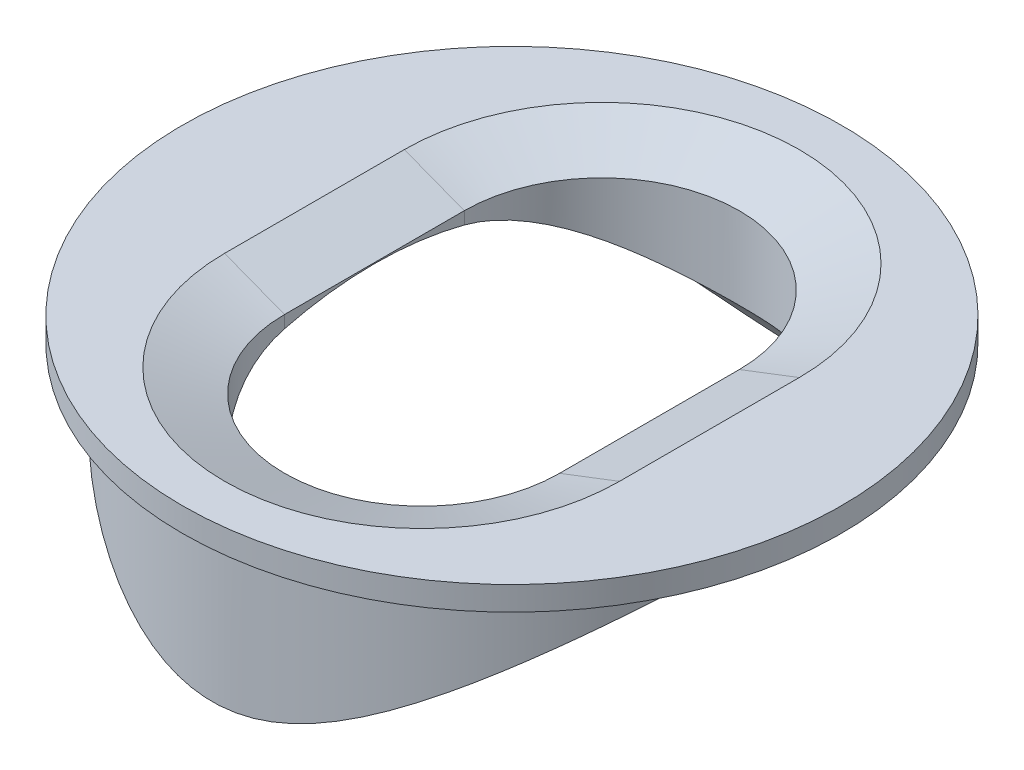
from build123d import *

# Parameters (mm, degrees)
SKETCH1_R               = 5
BOSS_EXTRUDE1_DEPTH     = 5
SKETCH2_R               = 5.5
BOSS_EXTRUDE2_DEPTH     = 0.4
CUT_EXTRUDE1_DEPTH      = 6.4
SKETCH5_R               = 6
CUT_EXTRUDE2_DEPTH      = 6.5
CUT_EXTRUDE2_DEPTH_BACK = 6.5
CHAMFER4_SIZE           = 1
CHAMFER4_SIZE2          = 0.383864035


with BuildPart() as part:
    # Sketch1 → Boss-Extrude1 (new body)
    with BuildSketch(Plane(origin=(0, 0, 0), x_dir=(1, 0, 0), z_dir=(0, 1, 0))):
        Circle(SKETCH1_R)
    extrude(amount=BOSS_EXTRUDE1_DEPTH)

    # Sketch2 → Boss-Extrude2 (add)
    with BuildSketch(Plane(origin=(0, 5, 0), x_dir=(1, 0, 0), z_dir=(0, 1, 0))):
        Circle(SKETCH2_R)
    extrude(amount=BOSS_EXTRUDE2_DEPTH)

    # Sketch4 → Cut-Extrude1 (cut, through all)
    with BuildSketch(Plane(origin=(0, 5.4, 0), x_dir=(1, 0, 0), z_dir=(0, 1, 0))):
        with BuildLine():
            Line((2.295250379, 1.5), (2.295250379, -1.5))
            ThreePointArc((2.295250379, -1.5), (0, -3.795250379), (-2.295250379, -1.5))
            Line((-2.295250379, -1.5), (-2.295250379, 1.5))
            ThreePointArc((-2.295250379, 1.5), (0, 3.795250379), (2.295250379, 1.5))
        make_face()
    extrude(amount=-CUT_EXTRUDE1_DEPTH, mode=Mode.SUBTRACT)

    # Sketch5 → Cut-Extrude2 (cut, two sides)
    with BuildSketch(Plane(origin=(0, 0, 0), x_dir=(0, 0, -1), z_dir=(1, 0, 0))) as cut_extrude2_sk:
        with Locations((0, -1)):
            Circle(SKETCH5_R)
    extrude(amount=CUT_EXTRUDE2_DEPTH, mode=Mode.SUBTRACT)
    extrude(cut_extrude2_sk.sketch, amount=-CUT_EXTRUDE2_DEPTH_BACK, mode=Mode.SUBTRACT)

    # Chamfer4
    chamfer4_edges = [part.edges().sort_by_distance(p)[0] for p in [
        (0, 5.4, -3.795250379),
        (-2.295250379, 5.4, 0),
        (0, 5.4, 3.795250379),
        (2.295250379, 5.4, 0),
    ]]
    chamfer4_side = [part.faces().sort_by_distance(p)[0] for p in [
        (-5.344436508, 5.4, 0),
    ]]
    chamfer(chamfer4_edges, length=CHAMFER4_SIZE, length2=CHAMFER4_SIZE2, reference=chamfer4_side[0])


solid = part.part
